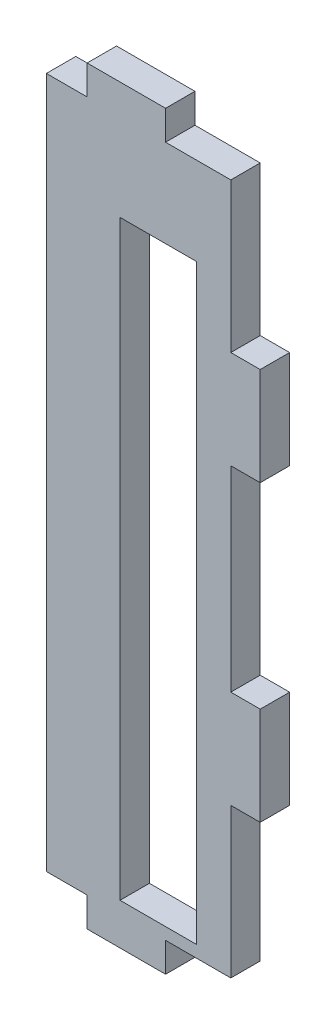
from build123d import *

# Parameters (mm, degrees)
SKETCH1_W           = 7.8
SKETCH1_H           = 60.325
BOSS_EXTRUDE1_DEPTH = 3
SKETCH2_W           = 2.5
SKETCH2_H           = 70.5
CUT_EXTRUDE1_DEPTH  = 3
SKETCH3_W           = 8
SKETCH3_H           = 3
BOSS_EXTRUDE2_DEPTH = 3


with BuildPart() as part:
    # Sketch1 → Boss-Extrude1 (new body)
    with BuildSketch(Plane.XY):
        Polygon((3, -10.75), (3, -0.75), (0, -0.75), (0, 19.25), (3, 19.25), (3, 29.25), (0, 29.25), (0, 42.5), (0, 44.5), (-21.311841589, 44.5), (-21.311841589, -26), (-19.311841589, -26), (-2, -26), (0, -26), (0, -24), (0, -10.75), align=None)
        with Locations((-7.4, 5.3775)):
            Rectangle(SKETCH1_W, SKETCH1_H, mode=Mode.SUBTRACT)
    extrude(amount=BOSS_EXTRUDE1_DEPTH)

    # Sketch2 → Cut-Extrude1 (cut)
    with BuildSketch(Plane.XY.offset(3)):
        with Locations((-20.061841589, 9.25)):
            Rectangle(SKETCH2_W, SKETCH2_H)
    extrude(amount=-CUT_EXTRUDE1_DEPTH, mode=Mode.SUBTRACT)

    # Sketch3 → Boss-Extrude2 (add)
    with BuildSketch(Plane.XY.offset(3)):
        with Locations((-10.655920795, -27.5)):
            Rectangle(SKETCH3_W, SKETCH3_H)
        with Locations((-10.655920795, 46)):
            Rectangle(SKETCH3_W, SKETCH3_H)
    extrude(amount=-BOSS_EXTRUDE2_DEPTH)


solid = part.part
